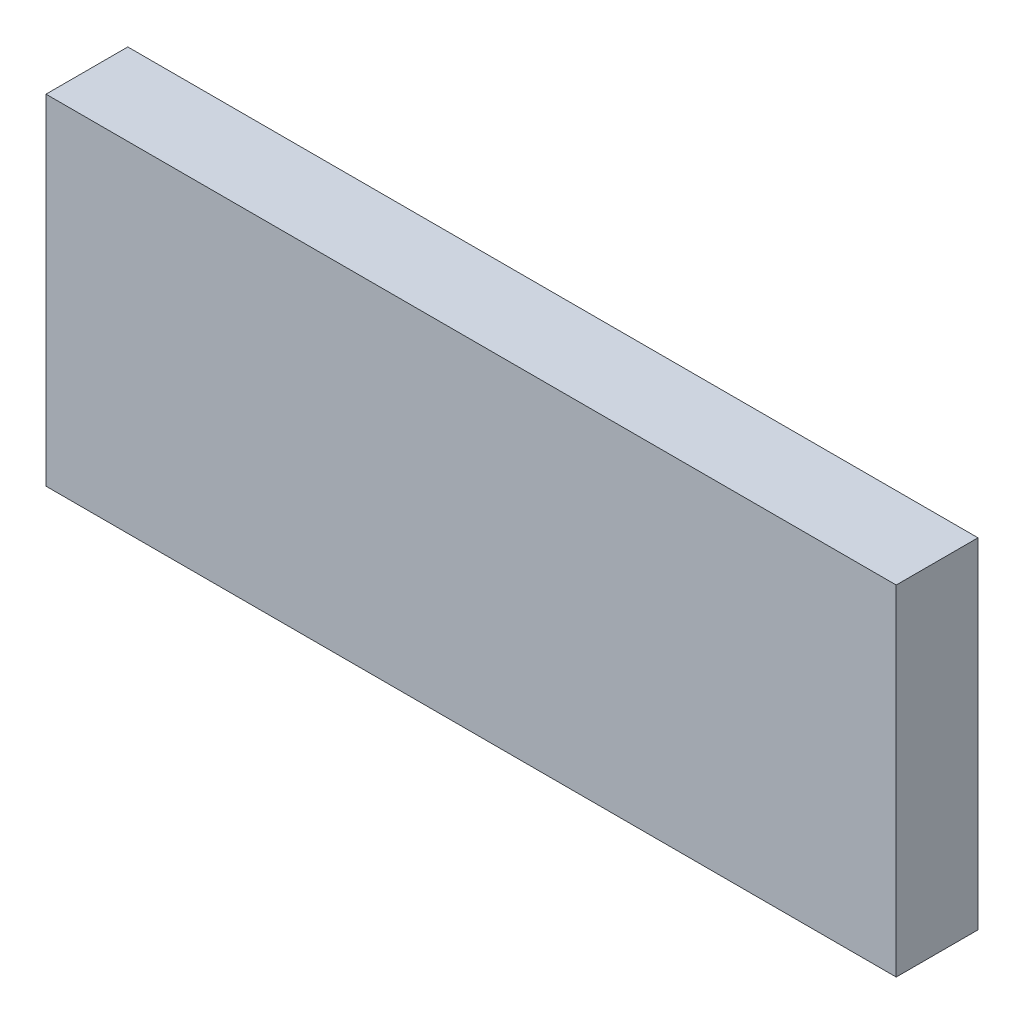
from build123d import *

# Parameters (mm, degrees)
SKETCH1_W           = 67.564
SKETCH1_H           = 6.49986
BOSS_EXTRUDE1_DEPTH = 26.98242


with BuildPart() as part:
    # Sketch1 → Boss-Extrude1 (new body)
    with BuildSketch(Plane(origin=(0, 0, 0), x_dir=(1, 0, 0), z_dir=(0, 1, 0))):
        with Locations((33.782, -3.24993)):
            Rectangle(SKETCH1_W, SKETCH1_H)
    extrude(amount=BOSS_EXTRUDE1_DEPTH)


solid = part.part
